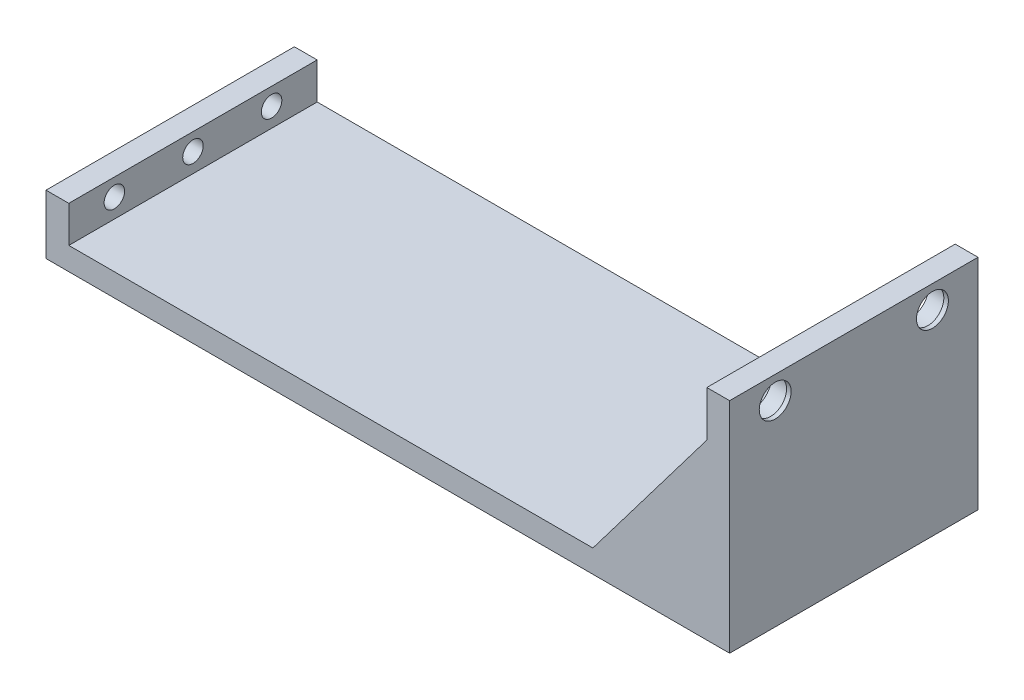
from build123d import *

# Parameters (mm, degrees)
SKETCH1_W                 = 150
SKETCH1_H                 = 54.5
BOSS_EXTRUDE1_DEPTH       = 5
SKETCH2_W                 = 5
SKETCH2_H                 = 54.5
BOSS_EXTRUDE2_DEPTH       = 8
F_8_CLEARANCE_HOLE1_D     = 4.4958
F_8_CLEARANCE_HOLE1_DEPTH = 17
F_8_CLEARANCE_HOLE1_TIP   = 1.350674586
SKETCH7_W                 = 5
SKETCH7_H                 = 54.5
BOSS_EXTRUDE3_DEPTH       = 43
SKETCH8_R                 = 4.25
CUT_EXTRUDE1_DEPTH        = 4
RIB1_REACH                = 120.085
SKETCH10_WALL_W           = 279.571445908
SKETCH10_WALL_H           = 10
RIB3_REACH                = 120.085
SKETCH12_WALL_W           = 279.571445908
SKETCH12_WALL_H           = 10
SKETCH13_W                = 8
SKETCH13_H                = 2
BOSS_EXTRUDE4_DEPTH       = 5
SKETCH14_R                = 2
CUT_EXTRUDE2_DEPTH        = 2
SKETCH15_R                = 3.5
CUT_EXTRUDE3_DEPTH        = 1


with BuildPart() as part:
    # Sketch1 → Boss-Extrude1 (new body)
    with BuildSketch(Plane(origin=(0, 0, 0), x_dir=(1, 0, 0), z_dir=(0, 1, 0))):
        with Locations((-18.112463826, -1.689393939)):
            Rectangle(SKETCH1_W, SKETCH1_H)
    extrude(amount=BOSS_EXTRUDE1_DEPTH)

    # Sketch2 → Boss-Extrude2 (add)
    with BuildSketch(Plane(origin=(0, 5, 0), x_dir=(1, 0, 0), z_dir=(0, 1, 0))):
        with Locations((-90.612463826, -1.689393939)):
            Rectangle(SKETCH2_W, SKETCH2_H)
    extrude(amount=BOSS_EXTRUDE2_DEPTH)

    # #8 Clearance Hole1
    with Locations(Plane(origin=(-93.112463826, 9.2, -15.560606061), x_dir=(0, 0, -1), z_dir=(-1, 0, 0))):
        with Locations((0, 0), (-17.25, 0), (-34.5, 0)):
            Hole(F_8_CLEARANCE_HOLE1_D / 2, depth=F_8_CLEARANCE_HOLE1_DEPTH)
            with Locations((0, 0, -(F_8_CLEARANCE_HOLE1_DEPTH + F_8_CLEARANCE_HOLE1_TIP / 2))):  # 118° drill point
                Cone(0, F_8_CLEARANCE_HOLE1_D / 2, F_8_CLEARANCE_HOLE1_TIP, mode=Mode.SUBTRACT)

    # Sketch7 → Boss-Extrude3 (add)
    with BuildSketch(Plane(origin=(0, 5, 0), x_dir=(1, 0, 0), z_dir=(0, 1, 0))):
        with Locations((54.387536174, -1.689393939)):
            Rectangle(SKETCH7_W, SKETCH7_H)
    extrude(amount=BOSS_EXTRUDE3_DEPTH)

    # Sketch8 → Cut-Extrude1 (cut)
    with BuildSketch(Plane.ZY.offset(-51.887536174)):
        with Locations((-15.560606061, 43)):
            Circle(SKETCH8_R)
        with Locations((18.939393939, 43)):
            Circle(SKETCH8_R)
    extrude(amount=-CUT_EXTRUDE1_DEPTH, mode=Mode.SUBTRACT)

    # Sketch10 wall → Rib1 (add, up to next)
    with BuildSketch(Plane(origin=(39.387536174, 21.5, -25.560606061), x_dir=(-0.603857687995, -0.797092148154, 0), z_dir=(-0.797092148154, 0.603857687995, 0)), mode=Mode.PRIVATE) as rib1_sk1:
        with Locations((0, 5)):
            Rectangle(SKETCH10_WALL_W, SKETCH10_WALL_H)
    rib1_tool1 = extrude(rib1_sk1.sketch, amount=-RIB1_REACH, mode=Mode.PRIVATE) - part.part
    add(rib1_tool1.solids().sort_by_distance((39.387536174, 21.5, -25.560606061))[0])

    # Sketch12 wall → Rib3 (add, up to next)
    with BuildSketch(Plane(origin=(39.387536174, 21.5, 28.939393939), x_dir=(-0.603857687995, -0.797092148154, 0), z_dir=(0.797092148154, -0.603857687995, 0)), mode=Mode.PRIVATE) as rib3_sk1:
        with Locations((0, 5)):
            Rectangle(SKETCH12_WALL_W, SKETCH12_WALL_H)
    rib3_tool1 = extrude(rib3_sk1.sketch, amount=RIB3_REACH, mode=Mode.PRIVATE) - part.part
    add(rib3_tool1.solids().sort_by_distance((39.387536174, 21.5, 28.939393939))[0])

    # Sketch13 → Boss-Extrude4 (add)
    with BuildSketch(Plane.ZY.offset(-51.887536174)):
        with Locations((1.689393939, 37)):
            Rectangle(SKETCH13_W, SKETCH13_H)
    extrude(amount=BOSS_EXTRUDE4_DEPTH)

    # Sketch14 → Cut-Extrude2 (cut)
    with BuildSketch(Plane(origin=(0, 38, 0), x_dir=(1, 0, 0), z_dir=(0, 1, 0))):
        with Locations(Location((49.387536174, -1.689393939, 0), (0, 0, 270))):
            Circle(SKETCH14_R)
    extrude(amount=-CUT_EXTRUDE2_DEPTH, mode=Mode.SUBTRACT)

    # Sketch15 → Cut-Extrude3 (cut)
    with BuildSketch(Plane.ZY.offset(-55.887536174)):
        with Locations((-15.560606061, 43)):
            Circle(SKETCH15_R)
        with Locations((18.939393939, 43)):
            Circle(SKETCH15_R)
    extrude(amount=-CUT_EXTRUDE3_DEPTH, mode=Mode.SUBTRACT)


solid = part.part
